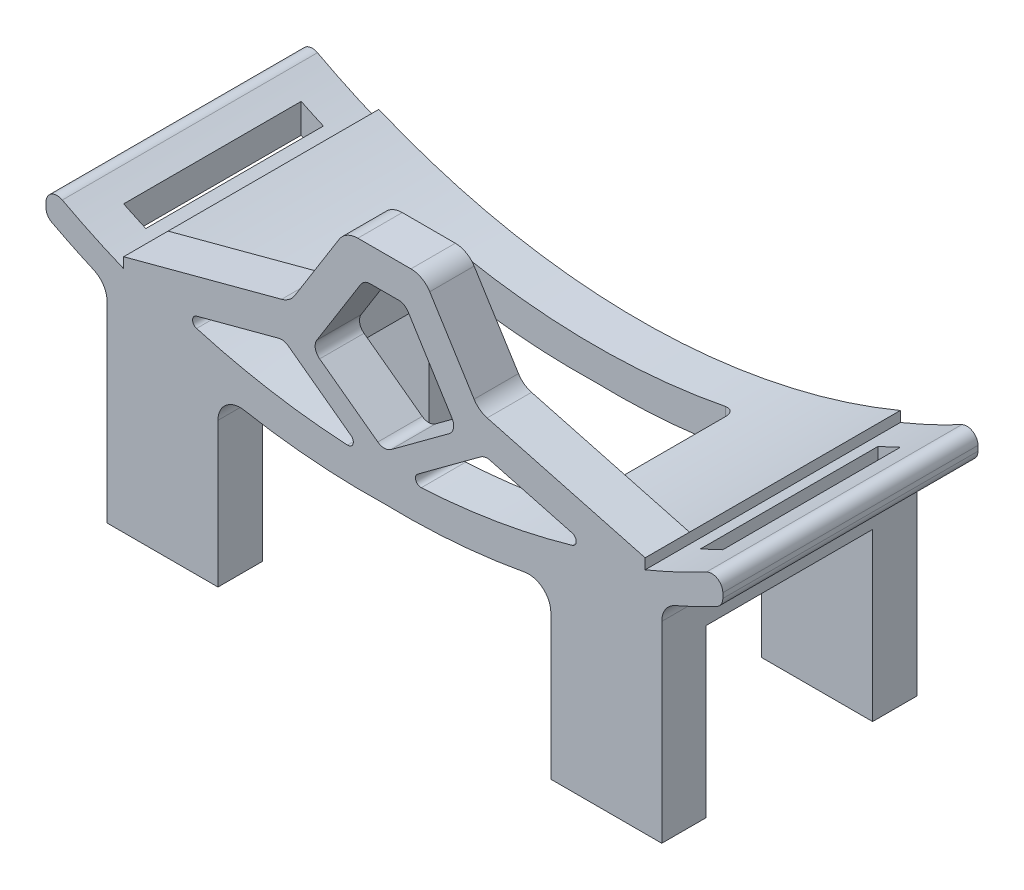
from build123d import *

# Parameters (mm, degrees)
SKETCH_1_W          = 61
SKETCH_1_H          = 4
EXTRUDE_1_DEPTH     = 15
EXTRUDE_1_2_DEPTH   = 15
SKETCH_2_W          = 61
SKETCH_2_H          = 23
EXTRUDE_2_DEPTH     = 4
EXTRUDE_3_DEPTH     = 23
CUT_EXTRUDE_1_DEPTH = 23
CUT_EXTRUDE_2_DEPTH = 23
CUT_EXTRUDE_3_DEPTH = 23
FILLET_1_R          = 1
SKETCH_9_W          = 2
SKETCH_9_H          = 16
CUT_EXTRUDE_4_DEPTH = 40
FILLET_2_R          = 1
SKETCH_10_W         = 25.473517425
SKETCH_10_H         = 15
CUT_EXTRUDE_5_DEPTH = 40
FILLET_3_R          = 1
EXTRUDE_4_DEPTH     = 4
CUT_EXTRUDE_6_DEPTH = 40


with BuildPart() as part:
    # 草图1 → 凸台-拉伸1 (new body)
    with BuildSketch(Plane(origin=(0, 0, 0), x_dir=(1, 0, 0), z_dir=(0, 1, 0))):
        with Locations((-29.49872666, -14.866833958)):
            Rectangle(SKETCH_1_W, SKETCH_1_H)
    extrude(amount=EXTRUDE_1_DEPTH)



with BuildPart() as body_2:
    # 草图1 → Extrude 1 2 (new body)
    with BuildSketch(Plane(origin=(0, 0, 0), x_dir=(1, 0, 0), z_dir=(0, 1, 0))):
        with Locations((-29.49872666, -33.866833958)):
            Rectangle(SKETCH_1_W, SKETCH_1_H)
    extrude(amount=EXTRUDE_1_2_DEPTH)


with BuildPart() as part_1:
    add(part.part)

    add(body_2.part)  # 凸台-拉伸2 merges body 2
    # 草图2 → 凸台-拉伸2 (add)
    with BuildSketch(Plane(origin=(0, 15, 0), x_dir=(1, 0, 0), z_dir=(0, 1, 0))):
        with Locations((-29.49872666, -24.366833958)):
            Rectangle(SKETCH_2_W, SKETCH_2_H)
    extrude(amount=EXTRUDE_2_DEPTH)

    # 草图3 → 凸台-拉伸3 (add)
    with BuildSketch(Plane.XY.offset(35.866833958)):
        with BuildLine():
            Line((-59.99872666, 25), (-59.99872666, 19))
            Line((-59.99872666, 19), (-45.633143428, 19))
            ThreePointArc((-45.633143428, 19), (-53.008133433, 21.539826341), (-59.99872666, 25))
        make_face()
        with BuildLine():
            ThreePointArc((1.00127334, 25), (-5.989319887, 21.539826341), (-13.364309893, 19))
            Line((-13.364309893, 19), (1.00127334, 19))
            Line((1.00127334, 19), (1.00127334, 25))
        make_face()
    extrude(amount=-EXTRUDE_3_DEPTH)

    # 草图4 → 切除-拉伸1 (cut)
    with BuildSketch(Plane.XY.offset(35.866833958)):
        with BuildLine():
            Line((-59.99872666, 25), (1.00127334, 25))
            ThreePointArc((1.00127334, 25), (-29.49872666, 16.827549631), (-59.99872666, 25))
        make_face()
    extrude(amount=-CUT_EXTRUDE_1_DEPTH, mode=Mode.SUBTRACT)

    # 草图7 → 切除-拉伸2 (cut)
    with BuildSketch(Plane.XY.offset(35.866833958)):
        with BuildLine():
            Line((-44.49872666, 0), (-29.49872666, 0))
            Line((-29.49872666, 0), (-29.49872666, 14))
            ThreePointArc((-29.49872666, 14), (-35.843538639, 14.163021123), (-42.13706744, 14.984428559))
            ThreePointArc((-42.13706744, 14.984428559), (-43.778703527, 14.554168766), (-44.49872666, 13.017399681))
            Line((-44.49872666, 13.017399681), (-44.49872666, 0))
        make_face()
        with BuildLine():
            Line((-54.49872666, 0), (-54.49872666, 17.322648745))
            ThreePointArc((-54.49872666, 17.322648745), (-54.823583781, 18.41530438), (-55.692622995, 19.15300305))
            ThreePointArc((-55.692622995, 19.15300305), (-57.866323827, 20.161752214), (-59.99872666, 21.255099523))
            Line((-59.99872666, 21.255099523), (-59.99872666, 0))
            Line((-59.99872666, 0), (-54.49872666, 0))
        make_face()
    cut_extrude_2 = extrude(amount=-CUT_EXTRUDE_2_DEPTH, mode=Mode.SUBTRACT)

    # 草图8 → 切除-拉伸3 (cut)
    with BuildSketch(Plane.XY.offset(35.866833958)):
        with BuildLine():
            Line((-59.99872666, 24), (-59.99872666, 25))
            Line((-59.99872666, 25), (-52.99872666, 25))
            Line((-52.99872666, 25), (-52.99872666, 20.59639466))
            ThreePointArc((-52.99872666, 20.59639466), (-56.552305579, 22.188004639), (-59.99872666, 24))
        make_face()
    cut_extrude_3 = extrude(amount=-CUT_EXTRUDE_3_DEPTH, mode=Mode.SUBTRACT)

    # 圆角1
    fillet_1_edges = [part_1.edges().sort_by_distance(p)[0] for p in [
        (-59.99872666, 21.255099523, 24.366833958),
        (-59.99872666, 24, 24.366833958),
    ]]
    fillet(fillet_1_edges, radius=FILLET_1_R)

    # 草图9 → 切除-拉伸4 (cut)
    with BuildSketch(Plane.XZ):
        with Locations((-55.49872666, 24.366833958)):
            Rectangle(SKETCH_9_W, SKETCH_9_H)
    cut_extrude_4 = extrude(amount=-CUT_EXTRUDE_4_DEPTH, mode=Mode.SUBTRACT)

    # 镜向3: 切除-拉伸2 across plane
    add(cut_extrude_2.mirror(Plane.ZY.offset(29.49872666)), mode=Mode.SUBTRACT)

    # 镜向4: 切除-拉伸3 across plane
    add(cut_extrude_3.mirror(Plane.ZY.offset(29.49872666)), mode=Mode.SUBTRACT)

    # 圆角2
    fillet_2_edges = [part_1.edges().sort_by_distance(p)[0] for p in [
        (1.00127334, 21.255099523, 24.366833958),
        (1.00127334, 24, 24.366833958),
    ]]
    fillet(fillet_2_edges, radius=FILLET_2_R)

    # 镜向7: 切除-拉伸4 across plane
    add(cut_extrude_4.mirror(Plane.ZY.offset(29.49872666)), mode=Mode.SUBTRACT)

    # 草图10 → 切除-拉伸5 (cut)
    with BuildSketch(Plane.XZ):
        with Locations((-29.498726661, 24.366833958)):
            Rectangle(SKETCH_10_W, SKETCH_10_H)
    extrude(amount=-CUT_EXTRUDE_5_DEPTH, mode=Mode.SUBTRACT)

    # 圆角3
    fillet_3_edges = [part_1.edges().sort_by_distance(p)[0] for p in [
        (-16.761967948, 16.586040333, 16.866833958),
        (-42.235485373, 16.586040333, 16.866833958),
        (-42.235485373, 16.586040333, 31.866833958),
        (-16.761967948, 16.586040333, 31.866833958),
    ]]
    fillet(fillet_3_edges, radius=FILLET_3_R)

    # 草图11 → 凸台-拉伸4 (add)
    with BuildSketch(Plane.XY.offset(35.866833958)):
        with BuildLine():
            Line((-52.99872666, 21.535898385), (-38.761178229, 25.332577966))
            ThreePointArc((-38.761178229, 25.332577966), (-38.087895944, 25.656566573), (-37.580506922, 26.205049966))
            Line((-37.580506922, 26.205049966), (-33.586227985, 32.595896265))
            ThreePointArc((-33.586227985, 32.595896265), (-32.859768442, 33.285183347), (-31.890231377, 33.535898385))
            Line((-31.890231377, 33.535898385), (-27.107221943, 33.535898385))
            ThreePointArc((-27.107221943, 33.535898385), (-26.137684878, 33.285183347), (-25.411225335, 32.595896265))
            Line((-25.411225335, 32.595896265), (-21.416946398, 26.205049966))
            ThreePointArc((-21.416946398, 26.205049966), (-20.909557376, 25.656566573), (-20.236275091, 25.332577966))
            Line((-20.236275091, 25.332577966), (-5.99872666, 21.535898385))
            ThreePointArc((-5.99872666, 21.535898385), (-29.49872666, 16.827549631), (-52.99872666, 21.535898385))
        make_face()
    extrude(amount=-EXTRUDE_4_DEPTH)

    # 草图13 → 切除-拉伸6 (cut)
    with BuildSketch(Plane.XY.offset(35.866833958)):
        with BuildLine():
            Line((-31.629734398, 30.065897325), (-35.591020119, 23.727840171))
            ThreePointArc((-35.591020119, 23.727840171), (-35.725277784, 23.010296005), (-35.336096399, 22.392693705))
            Line((-35.336096399, 22.392693705), (-30.091801244, 18.529726902))
            ThreePointArc((-30.091801244, 18.529726902), (-29.49872666, 18.334874428), (-28.905652077, 18.529726902))
            Line((-28.905652077, 18.529726902), (-23.661356922, 22.392693705))
            ThreePointArc((-23.661356922, 22.392693705), (-23.272175536, 23.010296005), (-23.406433201, 23.727840171))
            Line((-23.406433201, 23.727840171), (-27.367718922, 30.065897325))
            ThreePointArc((-27.367718922, 30.065897325), (-27.730948694, 30.410540866), (-28.215717226, 30.535898385))
            Line((-28.215717226, 30.535898385), (-30.781736094, 30.535898385))
            ThreePointArc((-30.781736094, 30.535898385), (-31.266504627, 30.410540866), (-31.629734398, 30.065897325))
        make_face()
        with BuildLine():
            Line((-39.022032341, 22.158181931), (-46.415604198, 20.186562769))
            ThreePointArc((-46.415604198, 20.186562769), (-46.786746411, 19.708589315), (-46.425517056, 19.2230808))
            ThreePointArc((-46.425517056, 19.2230808), (-39.690366454, 17.684965064), (-32.824491011, 16.918278649))
            ThreePointArc((-32.824491011, 16.918278649), (-32.326643896, 17.248573111), (-32.500693355, 17.820108732))
            Line((-32.500693355, 17.820108732), (-38.171295107, 21.997094517))
            ThreePointArc((-38.171295107, 21.997094517), (-38.578325126, 22.174488298), (-39.022032341, 22.158181931))
        make_face()
        with BuildLine():
            Line((-19.97542098, 22.158181931), (-12.581849122, 20.186562769))
            ThreePointArc((-12.581849122, 20.186562769), (-12.210706909, 19.708589315), (-12.571936264, 19.2230808))
            ThreePointArc((-12.571936264, 19.2230808), (-19.307086867, 17.684965064), (-26.17296231, 16.918278649))
            ThreePointArc((-26.17296231, 16.918278649), (-26.670809424, 17.248573111), (-26.496759965, 17.820108732))
            Line((-26.496759965, 17.820108732), (-20.826158214, 21.997094517))
            ThreePointArc((-20.826158214, 21.997094517), (-20.419128195, 22.174488298), (-19.97542098, 22.158181931))
        make_face()
    extrude(amount=-CUT_EXTRUDE_6_DEPTH, mode=Mode.SUBTRACT)


solid = part_1.part
